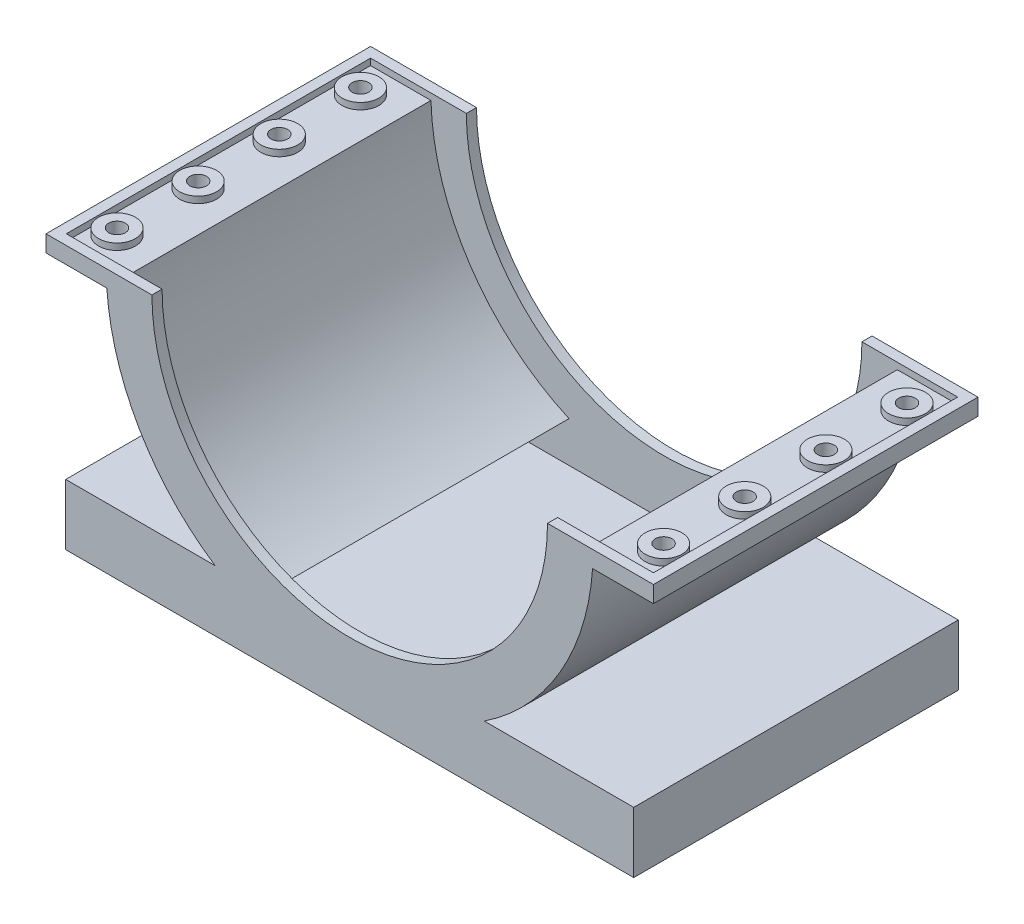
from build123d import *

# Parameters (mm, degrees)
BOSS_EXTRUDE2_DEPTH = 4
CUT_EXTRUDE2_REACH  = 8.5
SKETCH3_R           = 0.205
SHELL1_T            = -0.25


with BuildPart() as part:
    # Sketch1 → Boss-Extrude2 (new body, symmetric)
    with BuildSketch(Plane.XY):
        with BuildLine():
            Line((-7.485975276, 0), (-4.875, 0))
            ThreePointArc((-4.875, 0), (0, -4.875), (4.875, 0))
            Line((4.875, 0), (7.485975276, 0))
            Line((7.485975276, 0), (7.485975276, -0.41))
            Line((7.485975276, -0.41), (5.985975276, -0.41))
            ThreePointArc((5.985975276, -0.41), (5.186676874, -3.016352599), (3.31662479, -5))
            Line((3.31662479, -5), (7, -5))
            Line((7, -5), (7, -6.5))
            Line((7, -6.5), (-7, -6.5))
            Line((-7, -6.5), (-7, -5))
            Line((-7, -5), (-3.31662479, -5))
            ThreePointArc((-3.31662479, -5), (-5.186676874, -3.016352599), (-5.985975276, -0.41))
            Line((-5.985975276, -0.41), (-7.485975276, -0.41))
            Line((-7.485975276, -0.41), (-7.485975276, 0))
        make_face()
    extrude(amount=BOSS_EXTRUDE2_DEPTH, both=True)

    # Sketch3 → Cut-Extrude2 (cut, up to next)
    with BuildSketch(Plane(origin=(0, 0, 0), x_dir=(1, 0, 0), z_dir=(0, 1, 0)), mode=Mode.PRIVATE) as cut_extrude2_sk1:
        with Locations((-6.735975276, 3)):
            Circle(SKETCH3_R)
    cut_extrude2_tool1 = extrude(cut_extrude2_sk1.sketch, amount=-CUT_EXTRUDE2_REACH, mode=Mode.PRIVATE) & part.part
    add(cut_extrude2_tool1.solids().sort_by_distance((-6.735975, 0, -3))[0], mode=Mode.SUBTRACT)
    # Sketch3 → Cut-Extrude2 (cut, up to next)
    with BuildSketch(Plane(origin=(0, 0, 0), x_dir=(1, 0, 0), z_dir=(0, 1, 0)), mode=Mode.PRIVATE) as cut_extrude2_sk2:
        with Locations((-6.735975276, 1)):
            Circle(SKETCH3_R)
    cut_extrude2_tool2 = extrude(cut_extrude2_sk2.sketch, amount=-CUT_EXTRUDE2_REACH, mode=Mode.PRIVATE) & part.part
    add(cut_extrude2_tool2.solids().sort_by_distance((-6.735975, 0, -1))[0], mode=Mode.SUBTRACT)
    # Sketch3 → Cut-Extrude2 (cut, up to next)
    with BuildSketch(Plane(origin=(0, 0, 0), x_dir=(1, 0, 0), z_dir=(0, 1, 0)), mode=Mode.PRIVATE) as cut_extrude2_sk3:
        with Locations((-6.735975276, -1)):
            Circle(SKETCH3_R)
    cut_extrude2_tool3 = extrude(cut_extrude2_sk3.sketch, amount=-CUT_EXTRUDE2_REACH, mode=Mode.PRIVATE) & part.part
    add(cut_extrude2_tool3.solids().sort_by_distance((-6.735975, 0, 1))[0], mode=Mode.SUBTRACT)
    # Sketch3 → Cut-Extrude2 (cut, up to next)
    with BuildSketch(Plane(origin=(0, 0, 0), x_dir=(1, 0, 0), z_dir=(0, 1, 0)), mode=Mode.PRIVATE) as cut_extrude2_sk4:
        with Locations((-6.735975276, -3)):
            Circle(SKETCH3_R)
    cut_extrude2_tool4 = extrude(cut_extrude2_sk4.sketch, amount=-CUT_EXTRUDE2_REACH, mode=Mode.PRIVATE) & part.part
    add(cut_extrude2_tool4.solids().sort_by_distance((-6.735975, 0, 3))[0], mode=Mode.SUBTRACT)
    # Sketch3 → Cut-Extrude2 (cut, up to next)
    with BuildSketch(Plane(origin=(0, 0, 0), x_dir=(1, 0, 0), z_dir=(0, 1, 0)), mode=Mode.PRIVATE) as cut_extrude2_sk5:
        with Locations((6.735975276, -3)):
            Circle(SKETCH3_R)
    cut_extrude2_tool5 = extrude(cut_extrude2_sk5.sketch, amount=-CUT_EXTRUDE2_REACH, mode=Mode.PRIVATE) & part.part
    add(cut_extrude2_tool5.solids().sort_by_distance((6.735975, 0, 3))[0], mode=Mode.SUBTRACT)
    # Sketch3 → Cut-Extrude2 (cut, up to next)
    with BuildSketch(Plane(origin=(0, 0, 0), x_dir=(1, 0, 0), z_dir=(0, 1, 0)), mode=Mode.PRIVATE) as cut_extrude2_sk6:
        with Locations((6.735975276, -1)):
            Circle(SKETCH3_R)
    cut_extrude2_tool6 = extrude(cut_extrude2_sk6.sketch, amount=-CUT_EXTRUDE2_REACH, mode=Mode.PRIVATE) & part.part
    add(cut_extrude2_tool6.solids().sort_by_distance((6.735975, 0, 1))[0], mode=Mode.SUBTRACT)
    # Sketch3 → Cut-Extrude2 (cut, up to next)
    with BuildSketch(Plane(origin=(0, 0, 0), x_dir=(1, 0, 0), z_dir=(0, 1, 0)), mode=Mode.PRIVATE) as cut_extrude2_sk7:
        with Locations((6.735975276, 1)):
            Circle(SKETCH3_R)
    cut_extrude2_tool7 = extrude(cut_extrude2_sk7.sketch, amount=-CUT_EXTRUDE2_REACH, mode=Mode.PRIVATE) & part.part
    add(cut_extrude2_tool7.solids().sort_by_distance((6.735975, 0, -1))[0], mode=Mode.SUBTRACT)
    # Sketch3 → Cut-Extrude2 (cut, up to next)
    with BuildSketch(Plane(origin=(0, 0, 0), x_dir=(1, 0, 0), z_dir=(0, 1, 0)), mode=Mode.PRIVATE) as cut_extrude2_sk8:
        with Locations((6.735975276, 3)):
            Circle(SKETCH3_R)
    cut_extrude2_tool8 = extrude(cut_extrude2_sk8.sketch, amount=-CUT_EXTRUDE2_REACH, mode=Mode.PRIVATE) & part.part
    add(cut_extrude2_tool8.solids().sort_by_distance((6.735975, 0, -3))[0], mode=Mode.SUBTRACT)

    # Shell1
    shell1_openings = [part.faces().sort_by_distance(p)[0] for p in [
        (-6.735975276, 0, -0.795),
        (0, -2.4375, 0),
        (6.735975276, 0, 2.795),
    ]]
    offset(amount=SHELL1_T, openings=shell1_openings, kind=Kind.INTERSECTION)


solid = part.part
